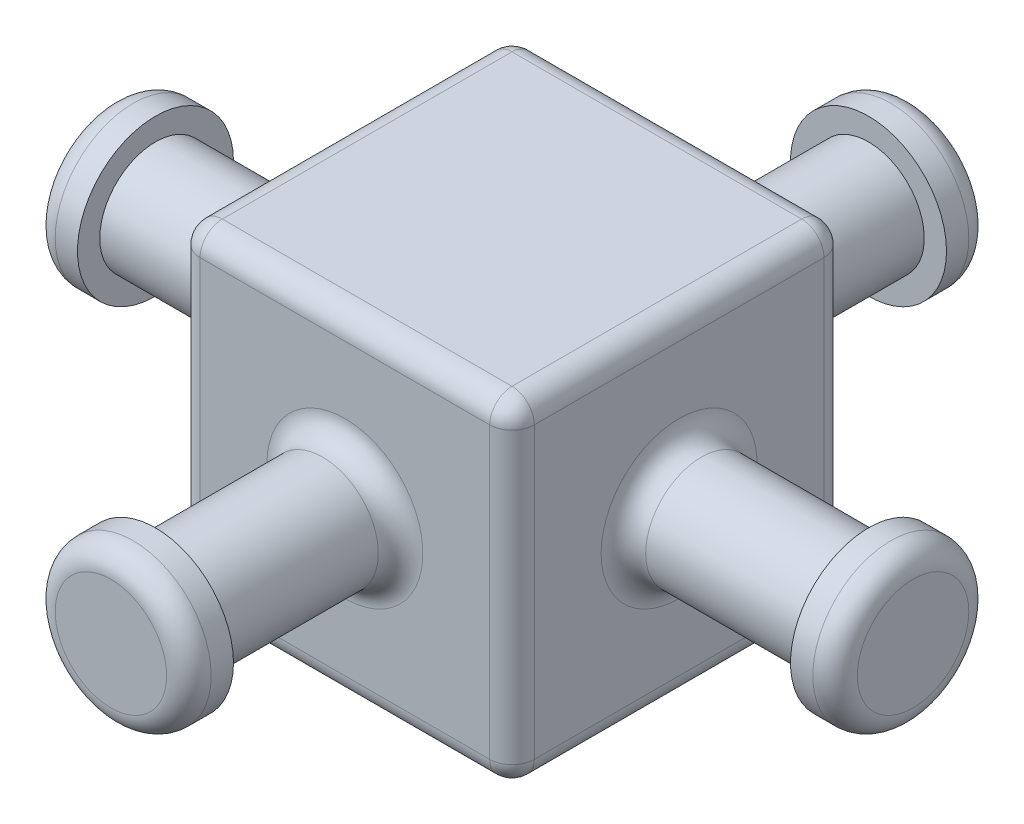
from build123d import *

# Parameters (mm, degrees)
SKETCH1_R            = 3.175
BOSS_EXTRUDE1_DEPTH  = 20.32
SKETCH2_R            = 4.445
BOSS_EXTRUDE2_DEPTH  = 2.54
FILLET1_R            = 1.27
FILLET1_OF_MIRROR1_R = 1.27
SKETCH3_R            = 3.175
BOSS_EXTRUDE3_DEPTH  = 20.32
SKETCH4_R            = 4.445
BOSS_EXTRUDE4_DEPTH  = 2.54
FILLET2_R            = 1.27
FILLET2_OF_MIRROR2_R = 1.27
SKETCH5_W            = 19.05
SKETCH5_H            = 19.05
BOSS_EXTRUDE5_DEPTH  = 9.525
FILLET3_R            = 1.27


with BuildPart() as part:
    # Sketch1 → Boss-Extrude1 (new body, symmetric)
    with BuildSketch(Plane.XY):
        Circle(SKETCH1_R)
    extrude(amount=BOSS_EXTRUDE1_DEPTH, both=True)

    # Sketch2 → Boss-Extrude2 (add)
    with BuildSketch(Plane.XY.offset(20.32)):
        Circle(SKETCH2_R)
    boss_extrude2 = extrude(amount=BOSS_EXTRUDE2_DEPTH)

    # Fillet1
    fillet1_edges = [part.edges().sort_by_distance(p)[0] for p in [
        (-4.445, 0, 22.86),
    ]]
    fillet(fillet1_edges, radius=FILLET1_R)

    # Mirror1: Boss-Extrude2 across plane
    add(boss_extrude2.mirror(Plane.XY))

    # Fillet1 of Mirror1
    fillet1_of_mirror1_edges = [part.edges().sort_by_distance(p)[0] for p in [
        (-4.445, 0, -22.86),
    ]]
    fillet(fillet1_of_mirror1_edges, radius=FILLET1_OF_MIRROR1_R)

    # Sketch3 → Boss-Extrude3 (add, symmetric)
    with BuildSketch(Plane(origin=(0, 0, 0), x_dir=(0, 0, -1), z_dir=(1, 0, 0))):
        Circle(SKETCH3_R)
    extrude(amount=BOSS_EXTRUDE3_DEPTH, both=True)

    # Sketch4 → Boss-Extrude4 (add)
    with BuildSketch(Plane(origin=(20.32, 0, 0), x_dir=(0, 0, -1), z_dir=(1, 0, 0))):
        Circle(SKETCH4_R)
    boss_extrude4 = extrude(amount=BOSS_EXTRUDE4_DEPTH)

    # Fillet2
    fillet2_edges = [part.edges().sort_by_distance(p)[0] for p in [
        (22.86, 0, 4.445),
    ]]
    fillet(fillet2_edges, radius=FILLET2_R)

    # Mirror2: Boss-Extrude4 across plane
    add(boss_extrude4.mirror(Plane(origin=(0, 0, 0), x_dir=(0, 0, 1), z_dir=(1, 0, 0))))

    # Fillet2 of Mirror2
    fillet2_of_mirror2_edges = [part.edges().sort_by_distance(p)[0] for p in [
        (-22.86, 0, 4.445),
    ]]
    fillet(fillet2_of_mirror2_edges, radius=FILLET2_OF_MIRROR2_R)

    # Sketch5 → Boss-Extrude5 (add, symmetric)
    with BuildSketch(Plane(origin=(0, 0, 0), x_dir=(0, 0, -1), z_dir=(1, 0, 0))):
        Rectangle(SKETCH5_W, SKETCH5_H)
    extrude(amount=BOSS_EXTRUDE5_DEPTH, both=True)

    # Fillet3
    fillet3_edges = [part.edges().sort_by_distance(p)[0] for p in [
        (9.525, 0, 3.175),
        (-3.175, 0, -9.525),
        (-3.175, 0, 9.525),
        (-9.525, 0, 9.525),
        (0, 9.525, 9.525),
        (-9.525, 0, -9.525),
        (0, -9.525, -9.525),
        (9.525, 0, -9.525),
        (9.525, 9.525, 0),
        (9.525, 0, 9.525),
        (9.525, -9.525, 0),
        (-9.525, 9.525, 0),
        (0, 9.525, -9.525),
        (-9.525, -9.525, 0),
        (0, -9.525, 9.525),
        (-9.525, 0, 3.175),
    ]]
    fillet(fillet3_edges, radius=FILLET3_R)


solid = part.part
